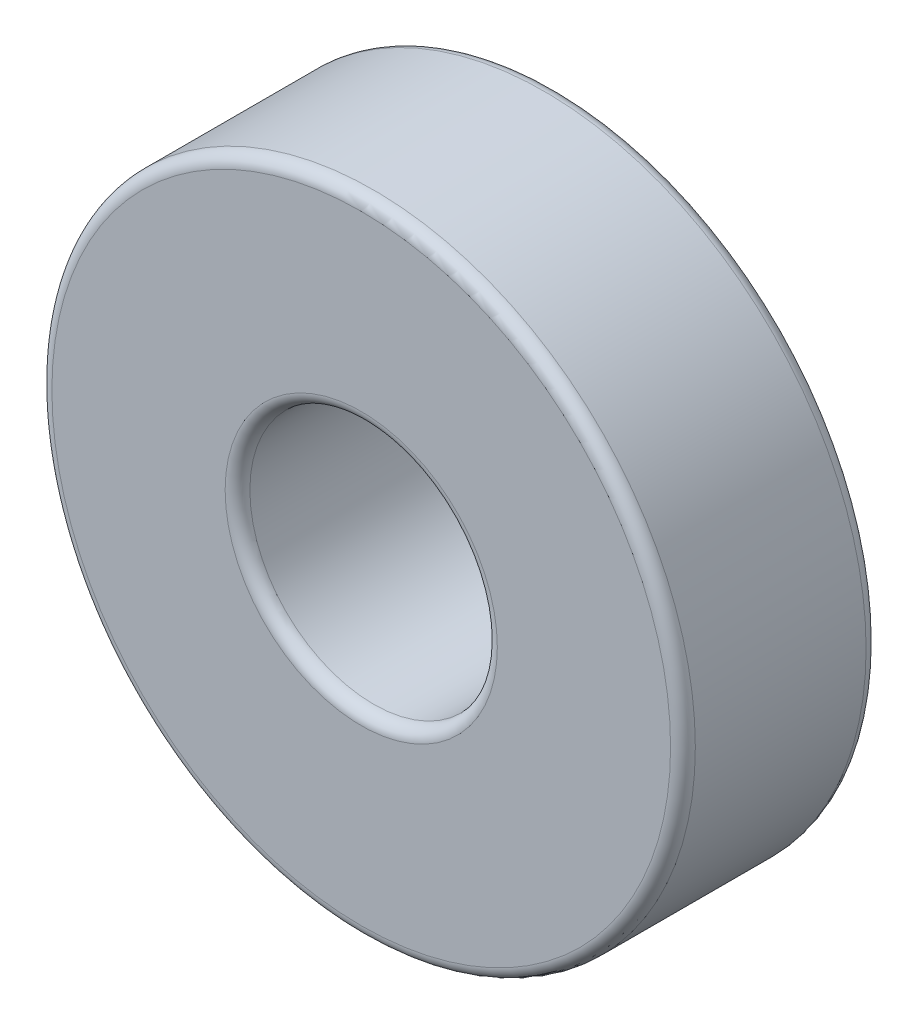
from build123d import *

# Parameters (mm, degrees)
SKETCH1_R           = 13
SKETCH1_R_2         = 5
BOSS_EXTRUDE1_DEPTH = 7.9
FILLET1_R           = 0.5


with BuildPart() as part:
    # Sketch1 → Boss-Extrude1 (new body)
    with BuildSketch(Plane.XY):
        Circle(SKETCH1_R)
        Circle(SKETCH1_R_2, mode=Mode.SUBTRACT)
    extrude(amount=BOSS_EXTRUDE1_DEPTH)

    # Fillet1
    fillet1_edges = [part.edges().sort_by_distance(p)[0] for p in [
        (-13, 0, 0),
        (-13, 0, 7.9),
        (-5, 0, 0),
        (-5, 0, 7.9),
    ]]
    fillet(fillet1_edges, radius=FILLET1_R)


solid = part.part
